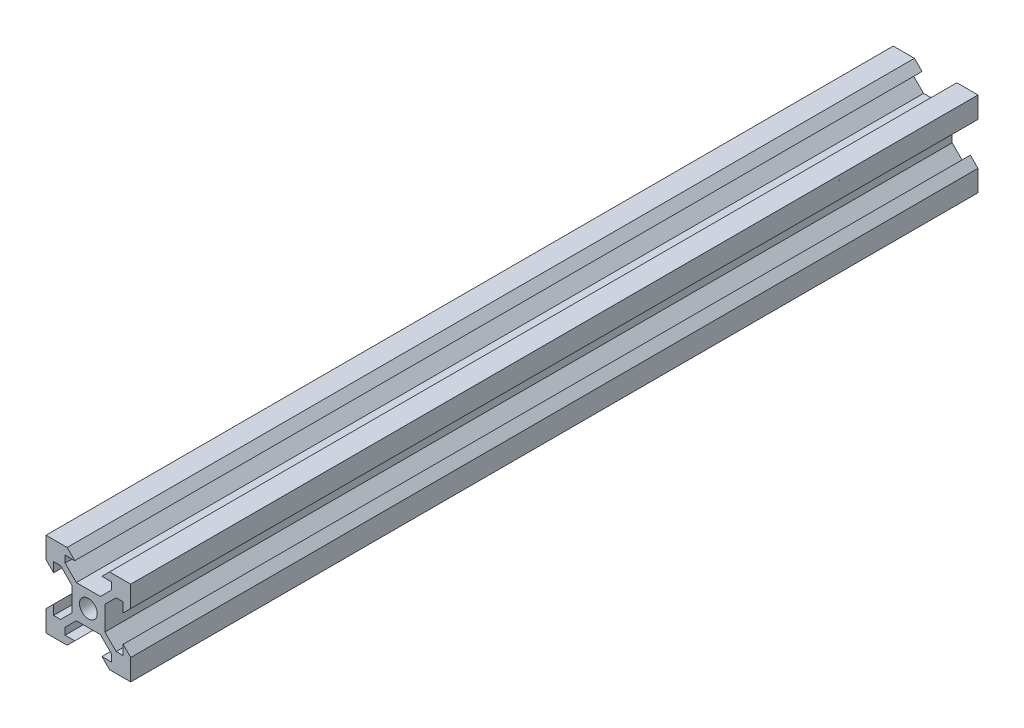
from build123d import *

# Parameters (mm, degrees)
SKETCH1_R           = 2.1
BOSS_EXTRUDE1_DEPTH = 100.0125


with BuildPart() as part:
    # Sketch1 → Boss-Extrude1 (new body, symmetric)
    with BuildSketch(Plane.XY):
        Polygon((-10, 10), (-5, 10), (-3.2, 8.2), (-5.499339828, 8.2), (-5.499339828, 6.56), (-2.84, 3.900660172), (2.84, 3.900660172), (5.499339828, 6.56), (5.499339828, 8.2), (3.2, 8.2), (5, 10), (10, 10), (10, 5), (8.2, 3.2), (8.2, 5.499339828), (6.56, 5.499339828), (3.900660172, 2.84), (3.900660172, -2.84), (6.56, -5.499339828), (8.2, -5.499339828), (8.2, -3.2), (10, -5), (10, -10), (5, -10), (3.2, -8.2), (5.499339828, -8.2), (5.499339828, -6.56), (2.84, -3.900660172), (-2.84, -3.900660172), (-5.499339828, -6.56), (-5.499339828, -8.2), (-3.2, -8.2), (-5, -10), (-10, -10), (-10, -5), (-8.2, -3.2), (-8.2, -5.499339828), (-6.56, -5.499339828), (-3.900660172, -2.84), (-3.900660172, 2.84), (-6.56, 5.499339828), (-8.2, 5.499339828), (-8.2, 3.2), (-10, 5), align=None)
        Circle(SKETCH1_R, mode=Mode.SUBTRACT)
    extrude(amount=BOSS_EXTRUDE1_DEPTH, both=True)


solid = part.part
